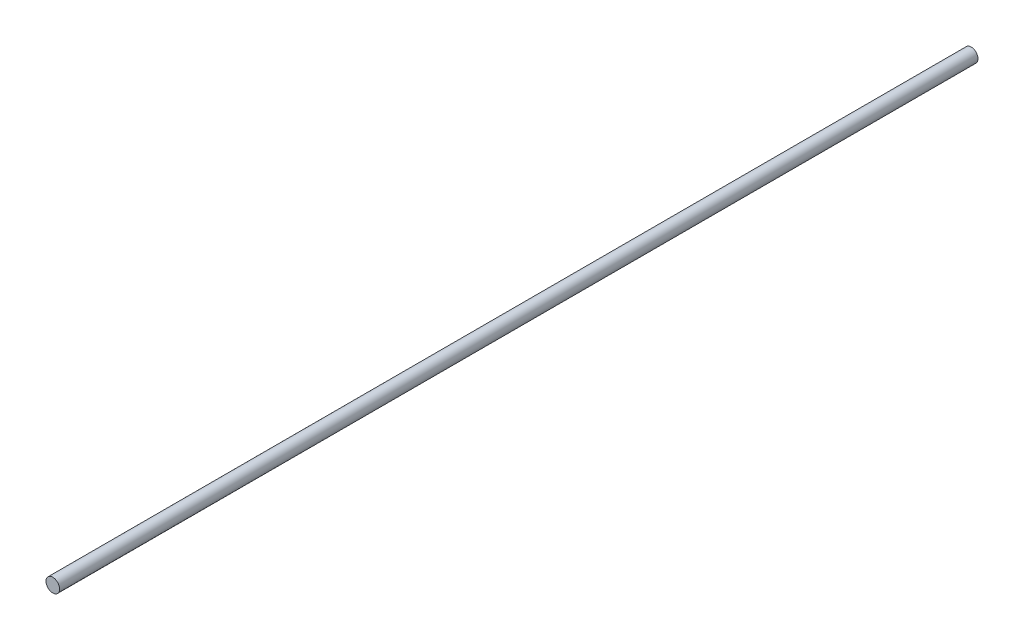
from build123d import *

# Parameters (mm, degrees)
SKETCH1_R           = 4
BOSS_EXTRUDE1_DEPTH = 540


with BuildPart() as part:
    # Sketch1 → Boss-Extrude1 (new body)
    with BuildSketch(Plane.XY):
        Circle(SKETCH1_R)
    extrude(amount=BOSS_EXTRUDE1_DEPTH)


solid = part.part
